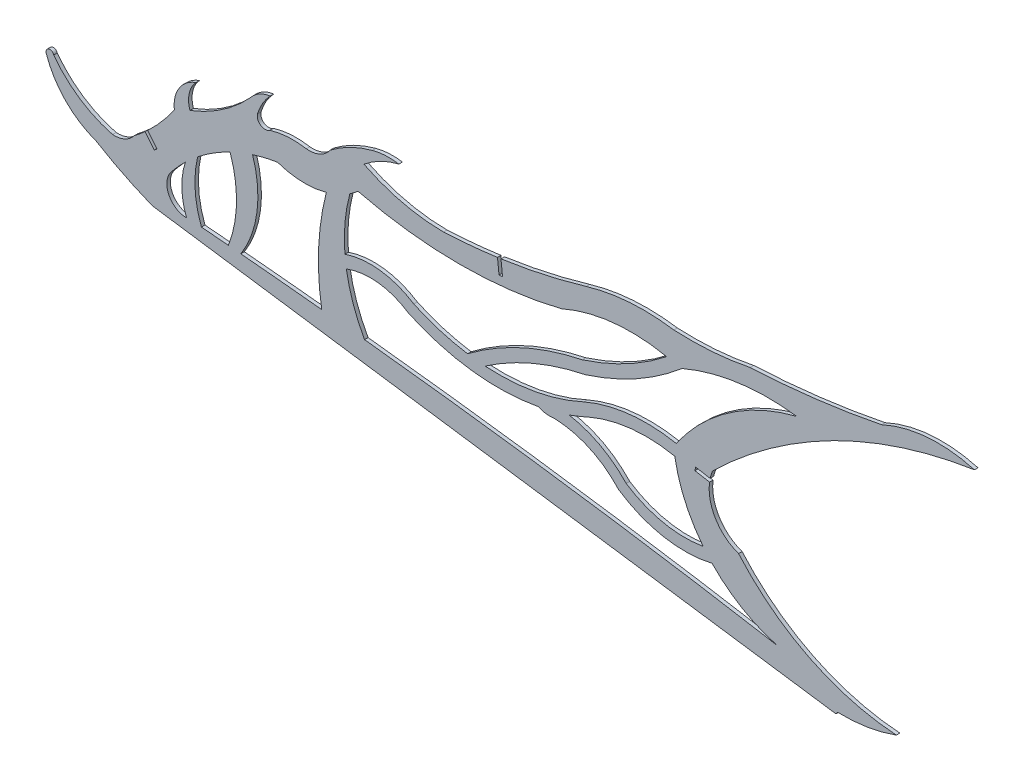
from build123d import *

# Parameters (mm, degrees)
BOSS_EXTRUDE1_DEPTH = 1.524


with BuildPart() as part:
    # Sketch1 → Boss-Extrude1 (new body)
    with BuildSketch(Plane.XY):
        with BuildLine():
            Line((299.496674555, 247.083909986), (293.228442315, 248.191486466))
            Line((293.228442315, 248.191486466), (292.963264261, 246.690734455))
            Line((292.963264261, 246.690734455), (299.231496501, 245.583157975))
            ThreePointArc((299.231496501, 245.583157975), (301.853890913, 233.138709027), (311.755483248, 225.157497886))
            ThreePointArc((311.755483248, 225.157497886), (342.378628376, 201.501430101), (379.736207542, 191.411938565))
            ThreePointArc((379.736207542, 191.411938565), (367.282944414, 188.133579217), (354.433282196, 187.286476253))
            ThreePointArc((354.433282196, 187.286476253), (354.075780486, 186.801693195), (353.711488573, 186.321991739))
            Line((353.711488573, 186.321991739), (59.210439319, 228.618287464))
            ThreePointArc((59.210439319, 228.618287464), (46.845732275, 234.131121821), (34.989718338, 240.66658328))
            ThreePointArc((34.989718338, 240.66658328), (21.739819765, 249.170959745), (13.469532472, 262.568219888))
            ThreePointArc((13.469532472, 262.568219888), (14.473805053, 264.820038124), (16.64661192, 263.65463729))
            ThreePointArc((16.64661192, 263.65463729), (27.881645016, 252.981360845), (42.038095614, 246.677417222))
            ThreePointArc((42.038095614, 246.677417222), (47.204267049, 247.59528857), (51.319192238, 250.850930717))
            ThreePointArc((51.319192238, 250.850930717), (53.712623356, 252.761043669), (56.030286878, 254.76241315))
            Line((56.030286878, 254.76241315), (60.009228178, 249.866621656))
            Line((60.009228178, 249.866621656), (61.191894588, 250.827806426))
            Line((61.191894588, 250.827806426), (57.156306316, 255.793297808))
            ThreePointArc((57.156306316, 255.793297808), (63.269330312, 262.174956241), (68.631929607, 269.198997493))
            ThreePointArc((68.631929607, 269.198997493), (70.672937053, 278.271974974), (77.97930542, 284.025375103))
            ThreePointArc((77.97930542, 284.025375103), (75.025286429, 278.530980407), (75.355674106, 272.301578731))
            ThreePointArc((75.355674106, 272.301578731), (89.522712553, 279.763084543), (101.575381834, 290.304062227))
            ThreePointArc((101.575381834, 290.304062227), (105.298186283, 293.444448732), (109.921107262, 294.977387738))
            ThreePointArc((109.921107262, 294.977387738), (106.645115294, 290.563839268), (104.441699592, 285.528316185))
            ThreePointArc((104.441699592, 285.528316185), (105.901175076, 281.967449489), (109.74705726, 282.10540072))
            ThreePointArc((109.74705726, 282.10540072), (117.575446144, 283.528434685), (125.519570472, 283.081683228))
            ThreePointArc((125.519570472, 283.081683228), (131.283660572, 283.993726612), (135.76973662, 287.726243123))
            ThreePointArc((135.76973662, 287.726243123), (144.425837897, 293.107350234), (153.959513951, 296.711989461))
            ThreePointArc((153.959513951, 296.711989461), (159.650281584, 297.625042258), (165.406340408, 297.331293248))
            ThreePointArc((165.406340408, 297.331293248), (157.435124743, 294.404562686), (150.340503018, 289.738475081))
            ThreePointArc((150.340503018, 289.738475081), (167.005302639, 283.674185668), (184.616227681, 281.589366329))
            ThreePointArc((184.616227681, 281.589366329), (196.264753754, 282.403178747), (207.864638646, 283.742253372))
            Line((207.864638646, 283.742253372), (208.536964433, 277.452860551))
            Line((208.536964433, 277.452860551), (210.052330785, 277.614850731))
            Line((210.052330785, 277.614850731), (209.374499216, 283.955748378))
            ThreePointArc((209.374499216, 283.955748378), (227.881790203, 287.319954151), (246.095409129, 292.02120779))
            ThreePointArc((246.095409129, 292.02120779), (264.837645669, 295.417547796), (283.869742792, 294.652149172))
            ThreePointArc((283.869742792, 294.652149172), (300.377514826, 294.830345717), (316.730515739, 297.09256867))
            ThreePointArc((316.730515739, 297.09256867), (345.164765747, 299.513120241), (373.338877641, 304.050196657))
            ThreePointArc((373.338877641, 304.050196657), (393.078041438, 309.22946311), (413.38768552, 307.235034456))
            ThreePointArc((413.38768552, 307.235034456), (377.376618301, 298.266191923), (343.59946469, 282.892806069))
            ThreePointArc((343.59946469, 282.892806069), (321.044455039, 268.037495843), (300.562470929, 250.433603398))
            ThreePointArc((300.562470929, 250.433603398), (299.951704088, 248.78353273), (299.496674555, 247.083909986))
        make_face()
        with BuildLine():
            ThreePointArc((328.489226954, 199.182421434), (239.736316258, 213.199295119), (150.587010018, 224.42217807))
            ThreePointArc((150.587010018, 224.42217807), (145.688890945, 235.30713064), (142.759093928, 246.878217553))
            ThreePointArc((142.759093928, 246.878217553), (156.400368795, 248.593878404), (169.314596837, 243.8768257))
            ThreePointArc((169.314596837, 243.8768257), (196.80467914, 235.971060868), (225.395801684, 236.839078326))
            ThreePointArc((225.395801684, 236.839078326), (228.814239063, 235.855643459), (232.370913957, 235.909698546))
            ThreePointArc((232.370913957, 235.909698546), (247.490619756, 232.384573367), (260.020733604, 223.217880511))
            ThreePointArc((260.020733604, 223.217880511), (279.392290374, 215.299092788), (300.31360184, 215.812061861))
            ThreePointArc((300.31360184, 215.812061861), (313.259683309, 205.562804926), (328.489226954, 199.182421434))
        make_face(mode=Mode.SUBTRACT)
        with BuildLine():
            ThreePointArc((73.889360105, 231.521400998), (66.254747612, 236.297695357), (67.210403263, 245.252415788))
            ThreePointArc((67.210403263, 245.252415788), (70.194674676, 248.739861019), (73.390521828, 252.034509875))
            ThreePointArc((73.390521828, 252.034509875), (71.857270881, 241.734604422), (73.889360105, 231.521400998))
        make_face(mode=Mode.SUBTRACT)
        with BuildLine():
            ThreePointArc((113.10156747, 271.864588213), (123.557739252, 269.880401171), (134.129074941, 271.111412263))
            ThreePointArc((134.129074941, 271.111412263), (130.799977878, 248.854403449), (132.142963674, 226.389904395))
            ThreePointArc((132.142963674, 226.389904395), (114.719074022, 228.137810366), (97.284812247, 229.779036204))
            ThreePointArc((97.284812247, 229.779036204), (104.267717835, 248.98290031), (102.357800113, 269.327471609))
            ThreePointArc((102.357800113, 269.327471609), (107.682050527, 270.797739485), (113.10156747, 271.864588213))
        make_face(mode=Mode.SUBTRACT)
        with BuildLine():
            ThreePointArc((147.76400458, 278.362692247), (191.575815975, 273.02026788), (235.390344097, 278.340365744))
            ThreePointArc((235.390344097, 278.340365744), (257.681856345, 284.318322066), (280.730860591, 283.138964891))
            ThreePointArc((280.730860591, 283.138964891), (263.443829779, 271.830407732), (244.408703812, 263.806139622))
            ThreePointArc((244.408703812, 263.806139622), (218.447725967, 255.331740571), (194.986699965, 241.354327761))
            ThreePointArc((194.986699965, 241.354327761), (183.145599945, 244.034647083), (171.789821421, 248.329068519))
            ThreePointArc((171.789821421, 248.329068519), (157.383066968, 253.59262513), (142.123022895, 252.046450178))
            ThreePointArc((142.123022895, 252.046450178), (142.159172604, 263.976764596), (144.269250711, 275.719050545))
            ThreePointArc((144.269250711, 275.719050545), (146.057798086, 276.986446261), (147.76400458, 278.362692247))
        make_face(mode=Mode.SUBTRACT)
        with BuildLine():
            ThreePointArc((287.393755321, 282.043602932), (311.637801497, 288.812820245), (336.809005326, 288.893911982))
            ThreePointArc((336.809005326, 288.893911982), (307.570989951, 275.586964292), (284.906320156, 252.821878241))
            ThreePointArc((284.906320156, 252.821878241), (264.644027419, 253.656561884), (245.053092851, 248.417049837))
            ThreePointArc((245.053092851, 248.417049837), (224.280647922, 241.798667768), (202.516617159, 240.524142565))
            ThreePointArc((202.516617159, 240.524142565), (223.186364423, 251.866283632), (245.694745472, 258.884502671))
            ThreePointArc((245.694745472, 258.884502671), (267.708759315, 268.367301705), (287.393755321, 282.043602932))
        make_face(mode=Mode.SUBTRACT)
        with BuildLine():
            ThreePointArc((92.637447972, 265.466743872), (95.417062565, 247.800095776), (91.910427153, 230.263271083))
            ThreePointArc((91.910427153, 230.263271083), (86.111065378, 230.774336481), (80.310675632, 231.273599578))
            ThreePointArc((80.310675632, 231.273599578), (77.567314948, 243.850784297), (78.665529568, 256.676755136))
            ThreePointArc((78.665529568, 256.676755136), (85.404291465, 261.464676125), (92.637447972, 265.466743872))
        make_face(mode=Mode.SUBTRACT)
        with BuildLine():
            ThreePointArc((284.256505511, 247.772083796), (265.390502286, 248.627841972), (247.136907632, 243.783806264))
            ThreePointArc((247.136907632, 243.783806264), (242.957516866, 241.976149158), (238.694255905, 240.376293737))
            ThreePointArc((238.694255905, 240.376293737), (252.104272767, 235.759131886), (263.342997343, 227.108247207))
            ThreePointArc((263.342997343, 227.108247207), (279.254554924, 220.502299636), (296.480474873, 220.212662162))
            ThreePointArc((296.480474873, 220.212662162), (288.629921984, 233.221231814), (284.256505511, 247.772083796))
        make_face(mode=Mode.SUBTRACT)
    extrude(amount=BOSS_EXTRUDE1_DEPTH)


solid = part.part
